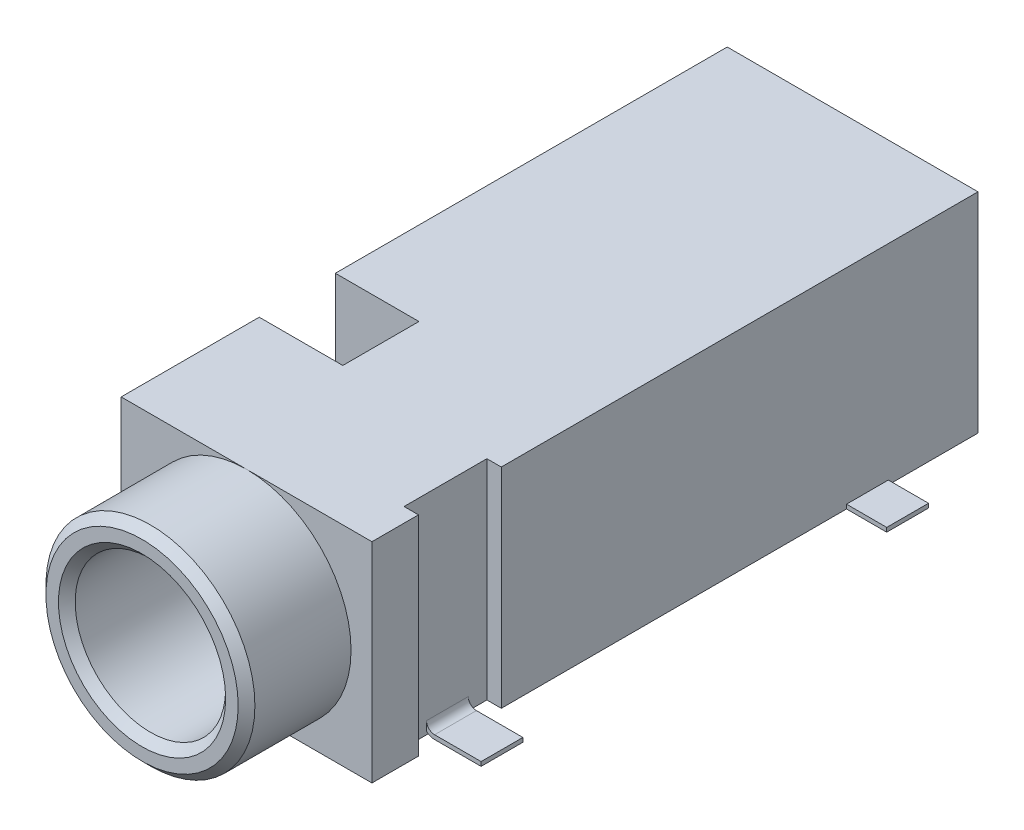
from build123d import *

# Parameters (mm, degrees)
SKETCH2_W                = 6
SKETCH2_H                = 14.5
BOSS_EXTRUDE1_DEPTH      = 5
SKETCH3_R                = 2.5
SKETCH3_R_2              = 1.8
BOSS_EXTRUDE2_DEPTH      = 2.5
CHAMFER2_SIZE            = 0.2
CHAMFER3_SIZE            = 0.2
SKETCH4_R                = 1.8
CUT_EXTRUDE1_DEPTH       = 14.02
SKETCH5_R                = 0.75
BOSS_EXTRUDE3_DEPTH      = 0.75
FILLET1_R                = 0.2
SKETCH7_W                = 0.344908333
SKETCH7_H                = 1.981698852
CUT_EXTRUDE2_DEPTH       = 12.710038429
SURFACE_EXTRUDE1_1_BACK  = 0.5
SURFACE_EXTRUDE1_1_DEPTH = 1
THICKEN1_T1              = 0.1
SKETCH9_W                = 1
SKETCH9_H                = 0.1
BOSS_EXTRUDE4_DEPTH      = 0.961518788
SURFACE_EXTRUDE2_2_BACK  = 0.5
SURFACE_EXTRUDE2_2_DEPTH = 1
THICKEN2_T2              = 0.1
SKETCH11_W               = 1.821073917
SKETCH11_H               = 5.660094607
CUT_EXTRUDE3_DEPTH       = 2


with BuildPart() as part:
    # Sketch2 → Boss-Extrude1 (new body)
    with BuildSketch(Plane(origin=(0, 0, 0), x_dir=(1, 0, 0), z_dir=(0, 1, 0))):
        Rectangle(SKETCH2_W, SKETCH2_H)
    extrude(amount=BOSS_EXTRUDE1_DEPTH)

    # Sketch3 → Boss-Extrude2 (add)
    with BuildSketch(Plane.XY.offset(7.25)):
        with Locations(Location((0, 2.5, 0), (0, 0, 270))):
            Circle(SKETCH3_R)
        with Locations((0, 2.5)):
            Circle(SKETCH3_R_2, mode=Mode.SUBTRACT)
    extrude(amount=BOSS_EXTRUDE2_DEPTH)

    # Chamfer2
    chamfer2_edges = [part.edges().sort_by_distance(p)[0] for p in [
        (0, 5, 9.75),
    ]]
    chamfer(chamfer2_edges, length=CHAMFER2_SIZE)

    # Chamfer3
    chamfer3_edges = [part.edges().sort_by_distance(p)[0] for p in [
        (-1.8, 2.5, 9.75),
    ]]
    chamfer(chamfer3_edges, length=CHAMFER3_SIZE)

    # Sketch4 → Cut-Extrude1 (cut)
    with BuildSketch(Plane.XY.offset(7.25)):
        with Locations((0, 2.5)):
            Circle(SKETCH4_R)
    extrude(amount=-CUT_EXTRUDE1_DEPTH, mode=Mode.SUBTRACT)

    # Sketch5 → Boss-Extrude3 (add)
    with BuildSketch(Plane.XZ):
        with Locations(Location((0, 4.191398765, 0), (0, 0, 90))):
            Circle(SKETCH5_R)
        with Locations(Location((0, -3.600413433, 0), (0, 0, 90))):
            Circle(SKETCH5_R)
    extrude(amount=BOSS_EXTRUDE3_DEPTH)

    # Fillet1
    fillet1_edges = [part.edges().sort_by_distance(p)[0] for p in [
        (0, -0.75, 3.441398765),
        (0, -0.75, -4.350413433),
    ]]
    fillet(fillet1_edges, radius=FILLET1_R)

    # Sketch7 → Cut-Extrude2 (cut, through all)
    with BuildSketch(Plane(origin=(0, 5, 0), x_dir=(1, 0, 0), z_dir=(0, 1, 0))):
        with Locations((2.827545834, -5.146058424)):
            Rectangle(SKETCH7_W, SKETCH7_H)
    extrude(amount=-CUT_EXTRUDE2_DEPTH, mode=Mode.SUBTRACT)

    # Surface-Extrude1: a surface, the sketch's curves swept straight by 1 mm
    with BuildLine(Plane.XY.offset(5.1).offset(-SURFACE_EXTRUDE1_1_BACK), mode=Mode.PRIVATE) as surface_extrude1_1_path:
        Line((2.555091667, 0.638024488), (2.555091667, 0.294273869))
        ThreePointArc((2.555091667, 0.294273869), (2.641282487, 0.086190821), (2.849365536, 0))
        Line((2.849365536, 0), (3.961518788, 0))
    surface_extrude1_1 = Shell.extrude(surface_extrude1_1_path.wire(), (0 * SURFACE_EXTRUDE1_1_DEPTH, 0 * SURFACE_EXTRUDE1_1_DEPTH, 1 * SURFACE_EXTRUDE1_1_DEPTH))
    add(Solid.thicken(surface_extrude1_1, THICKEN1_T1))

    # Sketch9 → Boss-Extrude4 (add)
    with BuildSketch(Plane(origin=(3, 0, 0), x_dir=(0, 0, -1), z_dir=(1, 0, 0))):
        with Locations((4.604659924, 0.05)):
            Rectangle(SKETCH9_W, SKETCH9_H)
    extrude(amount=BOSS_EXTRUDE4_DEPTH)

    # Surface-Extrude2: a surface, the sketch's curves swept straight by 1 mm
    with BuildLine(Plane.ZY.offset(-SURFACE_EXTRUDE2_2_BACK), mode=Mode.PRIVATE) as surface_extrude2_2_path:
        Line((-7.25, 2.862656565), (-7.25, 0.652010512))
        ThreePointArc((-7.25, 0.652010512), (-7.440969458, 0.190969458), (-7.902010512, 0))
        Line((-7.902010512, 0), (-9.009741204, 0))
    surface_extrude2_2 = Shell.extrude(surface_extrude2_2_path.wire(), (-1 * SURFACE_EXTRUDE2_2_DEPTH, 0 * SURFACE_EXTRUDE2_2_DEPTH, 0 * SURFACE_EXTRUDE2_2_DEPTH))
    add(Solid.thicken(surface_extrude2_2, -THICKEN2_T2))

    # Sketch11 → Cut-Extrude3 (cut)
    with BuildSketch(Plane.ZY.offset(3)):
        with Locations((3.036115989, 3.2980341)):
            Rectangle(SKETCH11_W, SKETCH11_H)
    extrude(amount=-CUT_EXTRUDE3_DEPTH, mode=Mode.SUBTRACT)


solid = part.part
